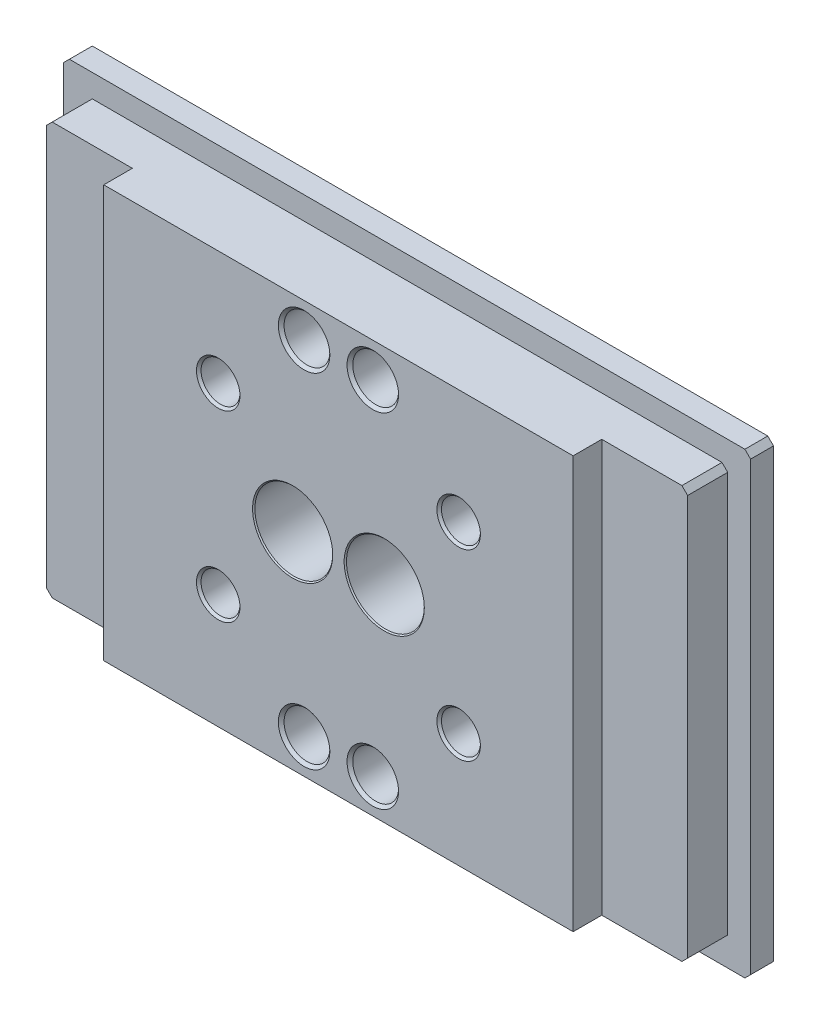
from build123d import *

# Parameters (mm, degrees)
SKETCH_1_W                        = 60
SKETCH_1_H                        = 40
EXTRUDE_1_DEPTH                   = 8
SKETCH_2_OUTSIDE_W                = 76.51
SKETCH_2_OUTSIDE_H                = 56.51
SKETCH_2_OUTSIDE_W_2              = 56
SKETCH_2_OUTSIDE_H_2              = 36
CUT_EXTRUDE_1_DEPTH               = 6
CHAMFER_1_SIZE                    = 0.5
HOLE_WIZARD_4_0_4_1_D             = 4
HOLE_WIZARD_4_0_4_1_DEPTH         = 4.5
HOLE_WIZARD_4_0_4_1_CSINK_D       = 4.5
HOLE_WIZARD_4_0_4_1_CSINK_ANGLE   = 90
HOLE_WIZARD_4_0_4_1_TIP           = 1.201721238
HOLE_WIZARD_M31_AT_2_COUNT        = 2
HOLE_WIZARD_M31_AT_2_PITCH        = 21
HOLE_WIZARD_M31_AT_3_COUNT        = 2
HOLE_WIZARD_M31_AT_3_PITCH        = 26.400757565
HOLE_WIZARD_M31_AT_4_COUNT        = 2
HOLE_WIZARD_M31_AT_4_PITCH        = 16
SKETCH_7_W                        = 7.5
SKETCH_7_H                        = 2.5
CUT_EXTRUDE_2_DEPTH               = 21
CUT_EXTRUDE_2_DEPTH_BACK          = 21
HOLE_WIZARD_6_8_6_8_1_D           = 6.8
HOLE_WIZARD_6_8_6_8_1_DEPTH       = 5
HOLE_WIZARD_6_8_6_8_1_CSINK_D     = 7
HOLE_WIZARD_6_8_6_8_1_CSINK_ANGLE = 90
HOLE_WIZARD_6_8_6_8_1_TIP         = 2.042926105


with BuildPart() as part:
    # Эскиз1 → Бобышка-Вытянуть1 (new body)
    with BuildSketch(Plane.XY):
        Rectangle(SKETCH_1_W, SKETCH_1_H)
    extrude(amount=EXTRUDE_1_DEPTH)

    # Эскиз2 outside → Вырез-Вытянуть1 (cut)
    with BuildSketch(Plane.XY.offset(8)):
        Rectangle(SKETCH_2_OUTSIDE_W, SKETCH_2_OUTSIDE_H)
        Rectangle(SKETCH_2_OUTSIDE_W_2, SKETCH_2_OUTSIDE_H_2, mode=Mode.SUBTRACT)
    extrude(amount=-CUT_EXTRUDE_1_DEPTH, mode=Mode.SUBTRACT)

    # Фаска1
    chamfer_1_edges = [part.edges().sort_by_distance(p)[0] for p in [
        (30, -20, 1),
        (-30, -20, 1),
        (-30, 20, 1),
        (30, 20, 1),
        (28, -18, 5),
        (-28, -18, 5),
        (-28, 18, 5),
        (28, 18, 5),
    ]]
    chamfer(chamfer_1_edges, length=CHAMFER_1_SIZE)

    # Диаметр отверстия Ø4.0 (4)1
    with Locations(Plane.XY.offset(8)):
        with Locations((-3, -15), (3, -15), (3, 15), (-3, 15)):
            CounterSinkHole(HOLE_WIZARD_4_0_4_1_D / 2, HOLE_WIZARD_4_0_4_1_CSINK_D / 2, depth=HOLE_WIZARD_4_0_4_1_DEPTH, counter_sink_angle=HOLE_WIZARD_4_0_4_1_CSINK_ANGLE)
            with Locations((0, 0, -(HOLE_WIZARD_4_0_4_1_DEPTH + HOLE_WIZARD_4_0_4_1_TIP / 2))):  # 118° drill point
                Cone(0, HOLE_WIZARD_4_0_4_1_D / 2, HOLE_WIZARD_4_0_4_1_TIP, mode=Mode.SUBTRACT)

    # Эскиз5 → Цековка для винта с внутренним шестигранником M31 (revolve, cut)
    with BuildSketch(Plane(origin=(10.5, 8, 0), x_dir=(0, 1, 0), z_dir=(1, 0, 0))):
        Polygon((0, 0), (0, 8), (1.9, 8), (1.7, 7.8), (1.7, 3.7), (1.9, 3.5), (3.25, 3.5), (3.25, 0.25), (3.5, 0), align=None)
    hole_wizard_m31 = revolve(axis=Axis((10.5, 8, -6.35), (0, 0, 1)), mode=Mode.SUBTRACT)

    # Цековка для винта с внутренним шестигранником M31 at 2: Цековка для винта с внутренним шестигранником M31 ×2
    with Locations(*[(-i * HOLE_WIZARD_M31_AT_2_PITCH, 0, 0) for i in range(1, HOLE_WIZARD_M31_AT_2_COUNT)]):
        add(hole_wizard_m31, mode=Mode.SUBTRACT)

    # Цековка для винта с внутренним шестигранником M31 at 3: Цековка для винта с внутренним шестигранником M31 ×2
    with Locations(*[Vector(-0.79543172, -0.606043215, 0) * (i * HOLE_WIZARD_M31_AT_3_PITCH) for i in range(1, HOLE_WIZARD_M31_AT_3_COUNT)]):
        add(hole_wizard_m31, mode=Mode.SUBTRACT)

    # Цековка для винта с внутренним шестигранником M31 at 4: Цековка для винта с внутренним шестигранником M31 ×2
    with Locations(*[(0, -i * HOLE_WIZARD_M31_AT_4_PITCH, 0) for i in range(1, HOLE_WIZARD_M31_AT_4_COUNT)]):
        add(hole_wizard_m31, mode=Mode.SUBTRACT)

    # Эскиз7 → Вырез-Вытянуть2 (cut, two sides)
    with BuildSketch(Plane(origin=(0, 0, 0), x_dir=(1, 0, 0), z_dir=(0, 1, 0))) as cut_extrude_2_sk:
        with Locations((24.25, -6.75)):
            Rectangle(SKETCH_7_W, SKETCH_7_H)
        with Locations((-24.25, -6.75)):
            Rectangle(SKETCH_7_W, SKETCH_7_H)
    extrude(amount=CUT_EXTRUDE_2_DEPTH, mode=Mode.SUBTRACT)
    extrude(cut_extrude_2_sk.sketch, amount=-CUT_EXTRUDE_2_DEPTH_BACK, mode=Mode.SUBTRACT)

    # Диаметр отверстия Ø6.8 (6.8)1
    with Locations(Plane.XY.offset(8)):
        with Locations((4, 0), (-4, 0)):
            CounterSinkHole(HOLE_WIZARD_6_8_6_8_1_D / 2, HOLE_WIZARD_6_8_6_8_1_CSINK_D / 2, depth=HOLE_WIZARD_6_8_6_8_1_DEPTH, counter_sink_angle=HOLE_WIZARD_6_8_6_8_1_CSINK_ANGLE)
            with Locations((0, 0, -(HOLE_WIZARD_6_8_6_8_1_DEPTH + HOLE_WIZARD_6_8_6_8_1_TIP / 2))):  # 118° drill point
                Cone(0, HOLE_WIZARD_6_8_6_8_1_D / 2, HOLE_WIZARD_6_8_6_8_1_TIP, mode=Mode.SUBTRACT)


solid = part.part
